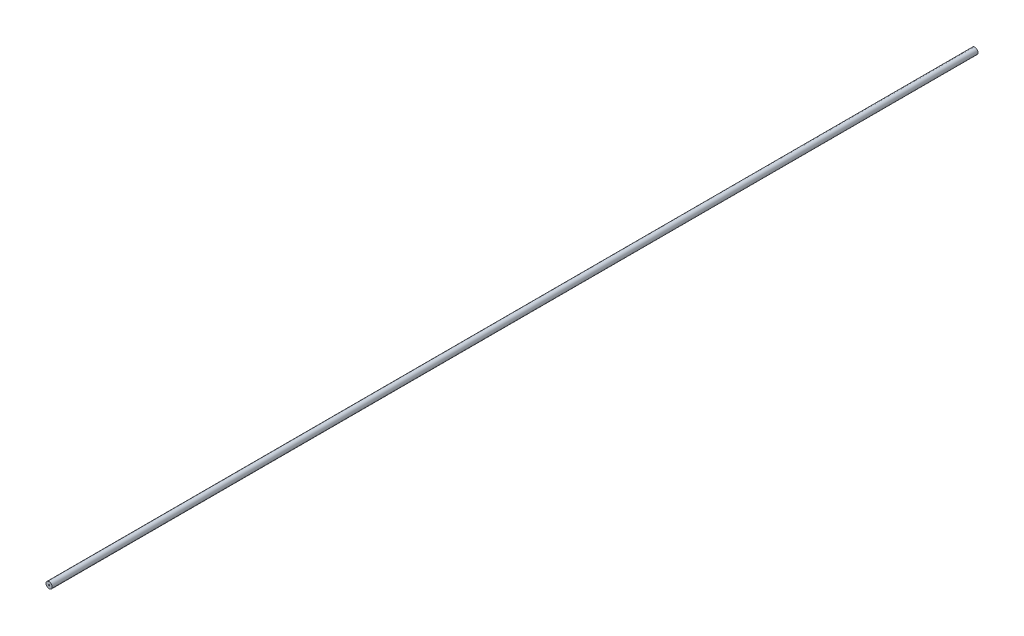
from build123d import *

# Parameters (mm, degrees)
SKETCH2_R           = 2.75
SKETCH2_R_2         = 0.5
BOSS_EXTRUDE1_DEPTH = 408.822965


with BuildPart() as part:
    # Sketch2 → Boss-Extrude1 (new, symmetric)
    with BuildSketch(Plane.XY):
        Circle(SKETCH2_R)
        Circle(SKETCH2_R_2, mode=Mode.SUBTRACT)
    extrude(amount=BOSS_EXTRUDE1_DEPTH, both=True)


solid = part.part
